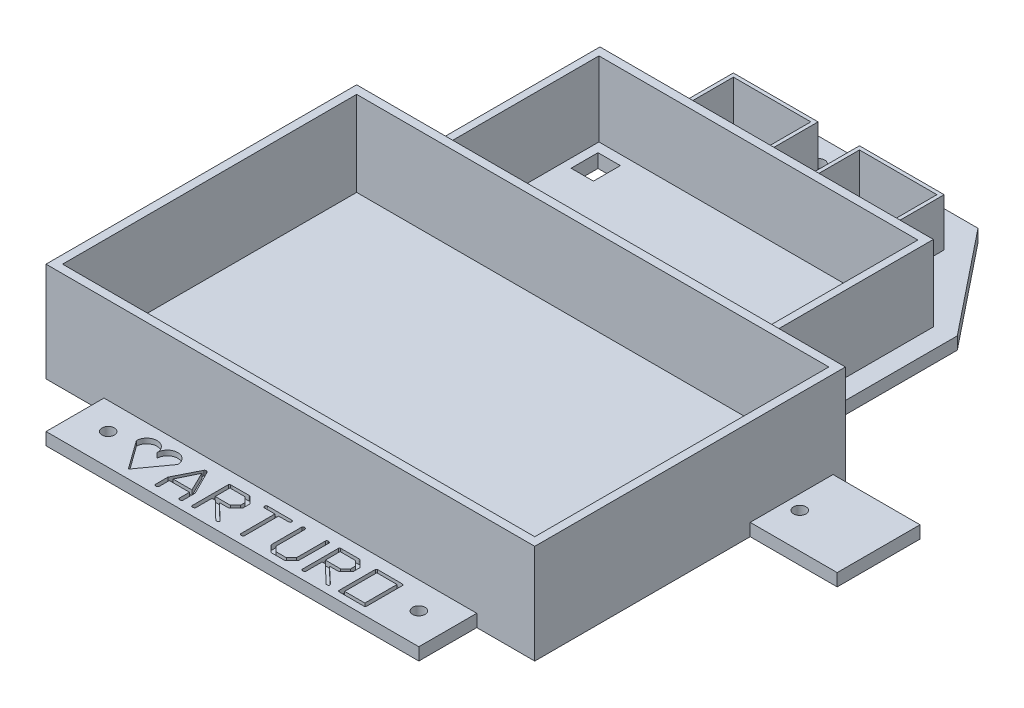
from build123d import *

# Parameters (mm, degrees)
SKETCH1_W           = 90
SKETCH1_H           = 145
BOSS_EXTRUDE1_DEPTH = 3
SKETCH3_W           = 35
SKETCH3_H           = 20
BOSS_EXTRUDE2_DEPTH = 3
SKETCH2_R           = 1.5
CUT_EXTRUDE1_DEPTH  = 3
SKETCH24_W          = 4.877009242
SKETCH24_H          = 7.758878341
CUT_EXTRUDE10_DEPTH = 1.2
SKETCH25_R          = 1.5
CUT_EXTRUDE11_DEPTH = 192.465401715
SKETCH27_W          = 80.5
SKETCH27_H          = 40
BOSS_EXTRUDE4_DEPTH = 18.3
SKETCH28_W          = 77
SKETCH28_H          = 36
CUT_EXTRUDE12_DEPTH = 18
SKETCH29_W          = 5.4
SKETCH29_H          = 6.5
CUT_EXTRUDE13_DEPTH = 18
SKETCH31_W          = 118
SKETCH31_H          = 75
BOSS_EXTRUDE5_DEPTH = 3
SKETCH32_W          = 118
SKETCH32_H          = 75
BOSS_EXTRUDE6_DEPTH = 18
SKETCH33_W          = 114
SKETCH33_H          = 71
CUT_EXTRUDE14_DEPTH = 20.5
SKETCH34_W          = 90
SKETCH34_H          = 3
BOSS_EXTRUDE7_DEPTH = 10
SKETCH35_W          = 20.45
SKETCH35_H          = 14.75
BOSS_EXTRUDE8_DEPTH = 11.55
SKETCH36_W          = 18.7
SKETCH36_H          = 13
CUT_EXTRUDE15_DEPTH = 11.55
CUT_EXTRUDE16_DEPTH = 11.55
CUT_EXTRUDE17_DEPTH = 11.55
SKETCH39_R          = 1.5
CUT_EXTRUDE19_DEPTH = 10


with BuildPart() as part:
    # Sketch1 → Boss-Extrude1 (new body)
    with BuildSketch(Plane(origin=(0, 0, 0), x_dir=(1, 0, 0), z_dir=(0, 1, 0))):
        with Locations((45, 72.5)):
            Rectangle(SKETCH1_W, SKETCH1_H)
    extrude(amount=BOSS_EXTRUDE1_DEPTH)

    # Sketch3 → Boss-Extrude2 (add)
    with BuildSketch(Plane(origin=(0, 3, 0), x_dir=(1, 0, 0), z_dir=(0, 1, 0))):
        with Locations((107.5, 76)):
            Rectangle(SKETCH3_W, SKETCH3_H)
        with Locations((-17.5, 76)):
            Rectangle(SKETCH3_W, SKETCH3_H)
    extrude(amount=-BOSS_EXTRUDE2_DEPTH)

    # Sketch2 → Cut-Extrude1 (cut)
    with BuildSketch(Plane(origin=(0, 3, 0), x_dir=(1, 0, 0), z_dir=(0, 1, 0))):
        with Locations(Location((7.5, 7.5, 0), (0, 0, 270))):
            Circle(SKETCH2_R)
        with Locations(Location((82.5, 7.5, 0), (0, 0, 270))):
            Circle(SKETCH2_R)
    extrude(amount=-CUT_EXTRUDE1_DEPTH, mode=Mode.SUBTRACT)

    # Sketch24 → Cut-Extrude10 (cut)
    with BuildSketch(Plane(origin=(0, 3, 0), x_dir=(1, 0, 0), z_dir=(0, 1, 0))):
        with BuildLine():
            Line((12.8, 9.002960052), (17.8, 2.06645569))
            Line((17.8, 2.06645569), (22.8, 9.002960052))
            ThreePointArc((22.8, 9.002960052), (20.3, 11.502960052), (17.8, 9.002960052))
            ThreePointArc((17.8, 9.002960052), (15.3, 11.502960052), (12.8, 9.002960052))
        make_face()
        with BuildLine():
            Line((27.960572726, 10.919890082), (30.899594276, 5.112854575))
            Line((30.899594276, 5.112854575), (30.899594276, 2.165173562))
            add(Edge.make_bspline(
                [(30.899594276, 2.165173562), (30.892927247, 2.140068414), (30.879954851, 2.091219979), (30.846858341, 2.024032213), (30.800737443, 1.967188076), (30.742020239, 1.921417495), (30.671236475, 1.886557094), (30.588439852, 1.863302375), (30.494943384, 1.847264506), (30.42859556, 1.845629109), (30.39388167, 1.844773452)],
                knots=[0, 0, 0, 0, 0.947643866, 1.843881502, 2.713660738, 3.599912128, 4.543320166, 5.577847846, 6.732704141, 8, 8, 8, 8], degree=3))
            add(Edge.make_bspline(
                [(30.39388167, 1.844773452), (30.344182078, 1.848546499), (30.248653133, 1.855798777), (30.138847489, 1.908146199), (30.070730608, 1.973741423), (30.03673257, 2.042634219), (30.015862164, 2.12641683), (30.013917243, 2.18753699), (30.012865323, 2.220594122)],
                knots=[0, 0, 0, 0, 1.458306385, 2.803050631, 3.475744591, 4.205244022, 5.029297625, 6, 6, 6, 6], degree=3))
            Line((30.012865323, 2.220594122), (30.012865323, 4.615801431))
            Line((30.012865323, 4.615801431), (25.13585608, 4.615801431))
            Line((25.13585608, 4.615801431), (25.132392295, 2.13573139))
            add(Edge.make_bspline(
                [(25.132392295, 2.13573139), (25.1242737, 2.109421365), (25.107472305, 2.054972891), (25.046353025, 1.987225122), (24.967328767, 1.92496232), (24.90233253, 1.895330988), (24.867412745, 1.879411302)],
                knots=[0, 0, 0, 0, 0.85446616, 1.768313713, 2.801007444, 4, 4, 4, 4], degree=3))
            add(Edge.make_bspline(
                [(24.867412745, 1.879411302), (24.856639425, 1.873655896), (24.830690772, 1.859793408), (24.779197205, 1.852562961), (24.713555929, 1.844731283), (24.664262831, 1.84475846), (24.637071044, 1.844773452)],
                knots=[0, 0, 0, 0, 0.618990669, 1.490902888, 2.615894787, 4, 4, 4, 4], degree=3))
            add(Edge.make_bspline(
                [(24.637071044, 1.844773452), (24.609854685, 1.845658545), (24.557815716, 1.847350885), (24.483497085, 1.863312057), (24.416757888, 1.889580371), (24.356389001, 1.925640528), (24.30553323, 1.97679588), (24.273040413, 2.047007647), (24.25207084, 2.131613072), (24.250159634, 2.193881759), (24.249127127, 2.227521692)],
                knots=[0, 0, 0, 0, 1.042871789, 1.994020302, 2.898665572, 3.783582711, 4.676223712, 5.617005175, 6.71261484, 8, 8, 8, 8], degree=3))
            Line((24.249127127, 2.227521692), (24.249127127, 2.362609306))
            Line((24.249127127, 2.362609306), (24.249127127, 5.164811349))
            Line((24.249127127, 5.164811349), (27.182953, 10.975310642))
            add(Edge.make_bspline(
                [(27.182953, 10.975310642), (27.197877117, 10.993849349), (27.229358055, 11.032954903), (27.294231669, 11.082063278), (27.376505657, 11.122430618), (27.437855453, 11.143979663), (27.470447152, 11.155427461)],
                knots=[0, 0, 0, 0, 0.825089278, 1.740443647, 2.79962467, 4, 4, 4, 4], degree=3))
            add(Edge.make_bspline(
                [(27.470447152, 11.155427461), (27.528625563, 11.153661236), (27.636139052, 11.150397258), (27.780169754, 11.104934835), (27.896812425, 11.03137778), (27.93945397, 10.956817158), (27.960572726, 10.919890082)],
                knots=[0, 0, 0, 0, 1.208227024, 2.232799106, 3.124771774, 4, 4, 4, 4], degree=3))
        make_face()
        Polygon((25.262284232, 5.391689265), (29.825820934, 5.391689265), (27.531063389, 10.072994656), align=None, mode=Mode.SUBTRACT)
        with BuildLine():
            Line((38.216840032, 10.992629567), (39.737441636, 9.461636609))
            Line((39.737441636, 9.461636609), (39.766883808, 9.32308521))
            Line((39.766883808, 9.32308521), (39.76168813, 7.800751714))
            Line((39.76168813, 7.800751714), (39.735709743, 7.71415709))
            Line((39.735709743, 7.71415709), (38.111194591, 6.129475464))
            Line((38.111194591, 6.129475464), (37.892976137, 6.05673598))
            Line((37.892976137, 6.05673598), (35.778335411, 6.05673598))
            Line((35.778335411, 6.05673598), (39.720122711, 2.331435241))
            add(Edge.make_bspline(
                [(39.720122711, 2.331435241), (39.731087028, 2.299853317), (39.748714944, 2.249077376), (39.761899762, 2.196987509), (39.766883808, 2.17729681)],
                knots=[0, 0, 0, 0, 1.243971999, 2, 2, 2, 2], degree=3))
            add(Edge.make_bspline(
                [(39.766883808, 2.17729681), (39.766883808, 2.174265998), (39.766883808, 2.170224915), (39.766883808, 2.173111403), (39.766883808, 2.173833025)],
                knots=[0, 0, 0, 0, 1.5, 2, 2, 2, 2], degree=3))
            add(Edge.make_bspline(
                [(39.766883808, 2.173833025), (39.771715245, 2.160766102), (39.780766869, 2.136285421), (39.781815136, 2.097906565), (39.766653287, 2.064033831), (39.7485569, 2.048521029), (39.739173528, 2.040477303)],
                knots=[0, 0, 0, 0, 1.11883269, 2.096116091, 3.012794686, 4, 4, 4, 4], degree=3))
            add(Edge.make_bspline(
                [(39.739173528, 2.040477303), (39.727566205, 2.020510557), (39.70201817, 1.976563202), (39.632985413, 1.925524496), (39.540428519, 1.880986933), (39.468813666, 1.857678145), (39.429164773, 1.844773452)],
                knots=[0, 0, 0, 0, 0.72925176, 1.605103046, 2.67408771, 4, 4, 4, 4], degree=3))
            add(Edge.make_bspline(
                [(39.429164773, 1.844773452), (39.388098016, 1.845041005), (39.313253724, 1.845528621), (39.212689442, 1.858192852), (39.132980278, 1.873757432), (39.091720454, 1.89593355), (39.074126813, 1.905389689)],
                knots=[0, 0, 0, 0, 1.351550787, 2.463205539, 3.344694023, 4, 4, 4, 4], degree=3))
            Line((39.074126813, 1.905389689), (34.806743726, 6.05673598))
            Line((34.806743726, 6.05673598), (34.003145612, 6.05673598))
            Line((34.003145612, 6.05673598), (34.00141372, 2.140927067))
            add(Edge.make_bspline(
                [(34.00141372, 2.140927067), (33.995298712, 2.118873879), (33.981853518, 2.070385079), (33.925548243, 2.005981454), (33.845912839, 1.941976341), (33.780964357, 1.903902874), (33.745093632, 1.882875087)],
                knots=[0, 0, 0, 0, 0.725058933, 1.594202014, 2.671289696, 4, 4, 4, 4], degree=3))
            add(Edge.make_bspline(
                [(33.745093632, 1.882875087), (33.732616994, 1.876419845), (33.704345012, 1.861792309), (33.649847394, 1.854717867), (33.582714396, 1.844008135), (33.532155747, 1.844501964), (33.504360576, 1.844773452)],
                knots=[0, 0, 0, 0, 0.680304615, 1.541565885, 2.648448938, 4, 4, 4, 4], degree=3))
            add(Edge.make_bspline(
                [(33.504360576, 1.844773452), (33.477144217, 1.845658545), (33.425105248, 1.847350885), (33.350786617, 1.863312057), (33.28404742, 1.889580371), (33.223678533, 1.925640528), (33.172822762, 1.97679588), (33.140329944, 2.047007647), (33.119360372, 2.131613072), (33.117449166, 2.193881759), (33.116416659, 2.227521692)],
                knots=[0, 0, 0, 0, 1.042871789, 1.994020302, 2.898665572, 3.783582711, 4.676223712, 5.617005175, 6.71261484, 8, 8, 8, 8], degree=3))
            Line((33.116416659, 2.227521692), (33.116416659, 10.880056555))
            add(Edge.make_bspline(
                [(33.116416659, 10.880056555), (33.127738551, 10.909639319), (33.149713789, 10.967058014), (33.205196118, 11.039896555), (33.277004064, 11.096824962), (33.334391503, 11.117185129), (33.364077285, 11.127717181)],
                knots=[0, 0, 0, 0, 1.036233373, 2.011278177, 2.971259878, 4, 4, 4, 4], degree=3))
            Line((33.364077285, 11.127717181), (33.691404965, 11.143304213))
            Line((33.691404965, 11.143304213), (37.80464962, 11.155427461))
            add(Edge.make_bspline(
                [(37.80464962, 11.155427461), (37.848147953, 11.153572045), (37.929929714, 11.150083653), (38.044855449, 11.120440638), (38.143044379, 11.068947661), (38.192578769, 11.017720115), (38.216840032, 10.992629567)],
                knots=[0, 0, 0, 0, 1.138914518, 2.141287496, 3.08962818, 4, 4, 4, 4], degree=3))
        make_face()
        Polygon((38.880154855, 9.168946778), (37.667830114, 10.379539627), (34.003145612, 10.379539627), (34.003145612, 6.832623814), (37.657438759, 6.832623814), (38.880154855, 8.053608017), align=None, mode=Mode.SUBTRACT)
        with BuildLine():
            add(Edge.make_bspline(
                [(48.197736433, 11.139840428), (48.248814606, 11.129237205), (48.343120312, 11.109660457), (48.463854134, 11.043454426), (48.546553845, 10.945291148), (48.564471284, 10.866382142), (48.573557103, 10.826367888)],
                knots=[0, 0, 0, 0, 1.181692692, 2.181760989, 3.077982587, 4, 4, 4, 4], degree=3))
            add(Edge.make_bspline(
                [(48.573557103, 10.826367888), (48.573025472, 10.798496471), (48.571968338, 10.74307481), (48.549008491, 10.662747651), (48.516655543, 10.585261926), (48.46765368, 10.51200439), (48.39351601, 10.447249055), (48.284248258, 10.408281557), (48.146427953, 10.383035937), (48.043187783, 10.380779691), (47.98644555, 10.379539627)],
                knots=[0, 0, 0, 0, 0.786245999, 1.56343179, 2.346953672, 3.158622924, 4.039912103, 5.081205552, 6.395789976, 8, 8, 8, 8], degree=3))
            Line((47.98644555, 10.379539627), (45.752304242, 10.379539627))
            Line((45.752304242, 10.379539627), (45.752304242, 2.13573139))
            add(Edge.make_bspline(
                [(45.752304242, 2.13573139), (45.737834969, 2.096976441), (45.708739433, 2.019046056), (45.608004208, 1.930437564), (45.473792562, 1.870149939), (45.370273455, 1.853696233), (45.314135443, 1.844773452)],
                knots=[0, 0, 0, 0, 0.875438603, 1.760375598, 2.785460327, 4, 4, 4, 4], degree=3))
            add(Edge.make_bspline(
                [(45.314135443, 1.844773452), (45.282342843, 1.84583333), (45.221893507, 1.847848546), (45.135437701, 1.861253902), (45.058533468, 1.885937494), (44.988796901, 1.918959951), (44.932166785, 1.972224275), (44.891473443, 2.04426098), (44.870524312, 2.135772027), (44.867314145, 2.202025445), (44.865575289, 2.237913047)],
                knots=[0, 0, 0, 0, 1.106735935, 2.104308933, 3.032056499, 3.912699536, 4.765629981, 5.692724586, 6.750214194, 8, 8, 8, 8], degree=3))
            Line((44.865575289, 2.237913047), (44.865575289, 10.379539627))
            Line((44.865575289, 10.379539627), (42.305838193, 10.379539627))
            add(Edge.make_bspline(
                [(42.305838193, 10.379539627), (42.277120088, 10.381743601), (42.219340145, 10.386177929), (42.138420452, 10.42735916), (42.069387205, 10.495113529), (42.033878093, 10.551828043), (42.014880256, 10.582171048)],
                knots=[0, 0, 0, 0, 0.920024065, 1.85106007, 2.850289155, 4, 4, 4, 4], degree=3))
            add(Edge.make_bspline(
                [(42.014880256, 10.582171048), (42.00629867, 10.61489633), (41.990925206, 10.673521966), (41.985918233, 10.733887116), (41.983706191, 10.760555974)],
                knots=[0, 0, 0, 0, 1.116415417, 2, 2, 2, 2], degree=3))
            add(Edge.make_bspline(
                [(41.983706191, 10.760555974), (41.984537517, 10.787221897), (41.986125841, 10.838169579), (42.002598162, 10.909724604), (42.025803592, 10.97430869), (42.063514459, 11.028120753), (42.109238813, 11.074771128), (42.165782125, 11.110765019), (42.231657539, 11.139708174), (42.280159584, 11.149986023), (42.305838193, 11.155427461)],
                knots=[0, 0, 0, 0, 1.135223372, 2.16894787, 3.120179468, 4.042274884, 4.947778528, 5.890363842, 6.883087883, 8, 8, 8, 8], degree=3))
            Line((42.305838193, 11.155427461), (48.197736433, 11.139840428))
        make_face()
        with BuildLine():
            add(Edge.make_bspline(
                [(51.602637062, 11.039390664), (51.623400792, 11.018351255), (51.665842492, 10.975346059), (51.710198178, 10.89002461), (51.732828892, 10.787716362), (51.736029497, 10.714481552), (51.737724676, 10.675693242)],
                knots=[0, 0, 0, 0, 0.882650724, 1.804165135, 2.836991241, 4, 4, 4, 4], degree=3))
            Line((51.737724676, 10.675693242), (51.737724676, 3.787956822))
            Line((51.737724676, 3.787956822), (52.911947782, 2.620661286))
            Line((52.911947782, 2.620661286), (55.40414107, 2.620661286))
            Line((55.40414107, 2.620661286), (56.614733918, 3.834717919))
            Line((56.614733918, 3.834717919), (56.614733918, 10.899107373))
            add(Edge.make_bspline(
                [(56.614733918, 10.899107373), (56.632890994, 10.932991956), (56.667688855, 10.997931434), (56.742769473, 11.077647621), (56.836168491, 11.132180866), (56.906189354, 11.146407269), (56.942061598, 11.153695568)],
                knots=[0, 0, 0, 0, 1.060672957, 2.032769508, 2.992172196, 4, 4, 4, 4], degree=3))
            add(Edge.make_bspline(
                [(56.942061598, 11.153695568), (56.981935287, 11.152266103), (57.057568148, 11.149554677), (57.16653719, 11.131866055), (57.261552996, 11.094021015), (57.347659955, 11.046833201), (57.416735255, 10.978727797), (57.469426213, 10.893284471), (57.495287126, 10.787358437), (57.499320469, 10.712168382), (57.501462872, 10.672229457)],
                knots=[0, 0, 0, 0, 1.13662016, 2.155953935, 3.124124809, 4.037977889, 4.933445915, 5.855694631, 6.861002965, 8, 8, 8, 8], degree=3))
            Line((57.501462872, 10.672229457), (57.451237989, 3.462361035))
            Line((57.451237989, 3.462361035), (55.821527159, 1.867288055))
            Line((55.821527159, 1.867288055), (55.582525996, 1.844773452))
            Line((55.582525996, 1.844773452), (52.539590897, 1.844773452))
            Line((52.539590897, 1.844773452), (52.427017886, 1.920976722))
            Line((52.427017886, 1.920976722), (50.88390168, 3.467556712))
            Line((50.88390168, 3.467556712), (50.850995723, 3.630354606))
            Line((50.850995723, 3.630354606), (50.850995723, 10.892179803))
            add(Edge.make_bspline(
                [(50.850995723, 10.892179803), (50.86578812, 10.927355571), (50.894278256, 10.995104051), (50.968942603, 11.077439753), (51.067054906, 11.13055661), (51.140210444, 11.145769747), (51.178323403, 11.153695568)],
                knots=[0, 0, 0, 0, 1.028909836, 1.981678895, 2.948484413, 4, 4, 4, 4], degree=3))
            add(Edge.make_bspline(
                [(51.178323403, 11.153695568), (51.223443517, 11.152514399), (51.307885706, 11.150303844), (51.42499893, 11.130576304), (51.524113787, 11.094884658), (51.577304562, 11.057293656), (51.602637062, 11.039390664)],
                knots=[0, 0, 0, 0, 1.208192095, 2.261128696, 3.171849697, 4, 4, 4, 4], degree=3))
        make_face()
        with BuildLine():
            Line((64.818708628, 10.992629567), (66.339310231, 9.461636609))
            Line((66.339310231, 9.461636609), (66.368752403, 9.32308521))
            Line((66.368752403, 9.32308521), (66.363556726, 7.800751714))
            Line((66.363556726, 7.800751714), (66.337578339, 7.71415709))
            Line((66.337578339, 7.71415709), (64.713063186, 6.129475464))
            Line((64.713063186, 6.129475464), (64.494844733, 6.05673598))
            Line((64.494844733, 6.05673598), (62.380204007, 6.05673598))
            Line((62.380204007, 6.05673598), (66.321991306, 2.331435241))
            add(Edge.make_bspline(
                [(66.321991306, 2.331435241), (66.332955623, 2.299853317), (66.350583539, 2.249077376), (66.363768357, 2.196987509), (66.368752403, 2.17729681)],
                knots=[0, 0, 0, 0, 1.243971999, 2, 2, 2, 2], degree=3))
            add(Edge.make_bspline(
                [(66.368752403, 2.17729681), (66.368752403, 2.174265998), (66.368752403, 2.170224915), (66.368752403, 2.173111403), (66.368752403, 2.173833025)],
                knots=[0, 0, 0, 0, 1.5, 2, 2, 2, 2], degree=3))
            add(Edge.make_bspline(
                [(66.368752403, 2.173833025), (66.373583841, 2.160766102), (66.382635465, 2.136285421), (66.383683732, 2.097906565), (66.368521883, 2.064033831), (66.350425495, 2.048521029), (66.341042124, 2.040477303)],
                knots=[0, 0, 0, 0, 1.11883269, 2.096116091, 3.012794686, 4, 4, 4, 4], degree=3))
            add(Edge.make_bspline(
                [(66.341042124, 2.040477303), (66.329434801, 2.020510557), (66.303886766, 1.976563202), (66.234854008, 1.925524496), (66.142297114, 1.880986933), (66.070682262, 1.857678145), (66.031033369, 1.844773452)],
                knots=[0, 0, 0, 0, 0.72925176, 1.605103046, 2.67408771, 4, 4, 4, 4], degree=3))
            add(Edge.make_bspline(
                [(66.031033369, 1.844773452), (65.989966612, 1.845041005), (65.915122319, 1.845528621), (65.814558037, 1.858192852), (65.734848874, 1.873757432), (65.693589049, 1.89593355), (65.675995409, 1.905389689)],
                knots=[0, 0, 0, 0, 1.351550787, 2.463205539, 3.344694023, 4, 4, 4, 4], degree=3))
            Line((65.675995409, 1.905389689), (61.408612322, 6.05673598))
            Line((61.408612322, 6.05673598), (60.605014208, 6.05673598))
            Line((60.605014208, 6.05673598), (60.603282315, 2.140927067))
            add(Edge.make_bspline(
                [(60.603282315, 2.140927067), (60.597167307, 2.118873879), (60.583722113, 2.070385079), (60.527416839, 2.005981454), (60.447781435, 1.941976341), (60.382832952, 1.903902874), (60.346962227, 1.882875087)],
                knots=[0, 0, 0, 0, 0.725058933, 1.594202014, 2.671289696, 4, 4, 4, 4], degree=3))
            add(Edge.make_bspline(
                [(60.346962227, 1.882875087), (60.334485589, 1.876419845), (60.306213607, 1.861792309), (60.25171599, 1.854717867), (60.184582991, 1.844008135), (60.134024342, 1.844501964), (60.106229172, 1.844773452)],
                knots=[0, 0, 0, 0, 0.680304615, 1.541565885, 2.648448938, 4, 4, 4, 4], degree=3))
            add(Edge.make_bspline(
                [(60.106229172, 1.844773452), (60.079012812, 1.845658545), (60.026973843, 1.847350885), (59.952655213, 1.863312057), (59.885916015, 1.889580371), (59.825547129, 1.925640528), (59.774691357, 1.97679588), (59.74219854, 2.047007647), (59.721228968, 2.131613072), (59.719317761, 2.193881759), (59.718285255, 2.227521692)],
                knots=[0, 0, 0, 0, 1.042871789, 1.994020302, 2.898665572, 3.783582711, 4.676223712, 5.617005175, 6.71261484, 8, 8, 8, 8], degree=3))
            Line((59.718285255, 2.227521692), (59.718285255, 10.880056555))
            add(Edge.make_bspline(
                [(59.718285255, 10.880056555), (59.729607147, 10.909639319), (59.751582385, 10.967058014), (59.807064714, 11.039896555), (59.878872659, 11.096824962), (59.936260099, 11.117185129), (59.96594588, 11.127717181)],
                knots=[0, 0, 0, 0, 1.036233373, 2.011278177, 2.971259878, 4, 4, 4, 4], degree=3))
            Line((59.96594588, 11.127717181), (60.29327356, 11.143304213))
            Line((60.29327356, 11.143304213), (64.406518216, 11.155427461))
            add(Edge.make_bspline(
                [(64.406518216, 11.155427461), (64.450016548, 11.153572045), (64.531798309, 11.150083653), (64.646724044, 11.120440638), (64.744912975, 11.068947661), (64.794447365, 11.017720115), (64.818708628, 10.992629567)],
                knots=[0, 0, 0, 0, 1.138914518, 2.141287496, 3.08962818, 4, 4, 4, 4], degree=3))
        make_face()
        Polygon((65.48202345, 9.168946778), (64.26969871, 10.379539627), (60.605014208, 10.379539627), (60.605014208, 6.832623814), (64.259307355, 6.832623814), (65.48202345, 8.053608017), align=None, mode=Mode.SUBTRACT)
        with BuildLine():
            add(Edge.make_bspline(
                [(74.872344513, 11.141572321), (74.917954597, 11.130654942), (75.002830944, 11.110338661), (75.113095511, 11.056016493), (75.195226305, 10.979572999), (75.222484374, 10.91542576), (75.236041935, 10.88352034)],
                knots=[0, 0, 0, 0, 1.198848019, 2.230950549, 3.120113869, 4, 4, 4, 4], degree=3))
            Line((75.236041935, 10.88352034), (75.236041935, 10.673961349))
            Line((75.236041935, 10.673961349), (75.23257815, 2.140927067))
            add(Edge.make_bspline(
                [(75.23257815, 2.140927067), (75.224646811, 2.116039226), (75.207750171, 2.063019066), (75.152300742, 1.992187906), (75.075063377, 1.924775524), (75.012241674, 1.88757213), (74.977989955, 1.867288055)],
                knots=[0, 0, 0, 0, 0.810066725, 1.725736988, 2.760023768, 4, 4, 4, 4], degree=3))
            Line((74.977989955, 1.867288055), (74.813460169, 1.844773452))
            Line((74.813460169, 1.844773452), (68.834967304, 1.844773452))
            add(Edge.make_bspline(
                [(68.834967304, 1.844773452), (68.805392619, 1.858600534), (68.74893592, 1.88499579), (68.677051959, 1.943044593), (68.619511242, 2.012591087), (68.596935768, 2.06800907), (68.585574786, 2.095897863)],
                knots=[0, 0, 0, 0, 1.069880941, 2.042352972, 3.014825004, 4, 4, 4, 4], degree=3))
            Line((68.585574786, 2.095897863), (68.585574786, 2.362609306))
            Line((68.585574786, 2.362609306), (68.585574786, 10.892179803))
            add(Edge.make_bspline(
                [(68.585574786, 10.892179803), (68.597620512, 10.922708884), (68.621770589, 10.983915632), (68.693012817, 11.058461124), (68.785264924, 11.118876496), (68.858413187, 11.142737517), (68.897315434, 11.155427461)],
                knots=[0, 0, 0, 0, 0.917586887, 1.839639645, 2.85106129, 4, 4, 4, 4], degree=3))
            Line((68.897315434, 11.155427461), (74.872344513, 11.141572321))
        make_face()
        with Locations((71.910808361, 6.500100457)):
            Rectangle(SKETCH24_W, SKETCH24_H, mode=Mode.SUBTRACT)
    extrude(amount=-CUT_EXTRUDE10_DEPTH, mode=Mode.SUBTRACT)

    # Sketch25 → Cut-Extrude11 (cut, through all)
    with BuildSketch(Plane(origin=(0, 3, 0), x_dir=(1, 0, 0), z_dir=(0, 1, 0))):
        with Locations(Location((-17.46875749, 74.5, 0), (0, 0, 270))):
            Circle(SKETCH25_R)
        with Locations(Location((107.46875749, 74.5, 0), (0, 0, 270))):
            Circle(SKETCH25_R)
    extrude(amount=-CUT_EXTRUDE11_DEPTH, mode=Mode.SUBTRACT)

    # Sketch27 → Boss-Extrude4 (add)
    with BuildSketch(Plane(origin=(0, 3, 0), x_dir=(1, 0, 0), z_dir=(0, 1, 0))):
        with Locations((45, 108.98)):
            Rectangle(SKETCH27_W, SKETCH27_H)
    extrude(amount=BOSS_EXTRUDE4_DEPTH)

    # Sketch28 → Cut-Extrude12 (cut)
    with BuildSketch(Plane(origin=(0, 21.3, 0), x_dir=(1, 0, 0), z_dir=(0, 1, 0))):
        with Locations((45, 108.98)):
            Rectangle(SKETCH28_W, SKETCH28_H)
    extrude(amount=-CUT_EXTRUDE12_DEPTH, mode=Mode.SUBTRACT)

    # Sketch29 → Cut-Extrude13 (cut)
    with BuildSketch(Plane(origin=(0, 3.3, 0), x_dir=(1, 0, 0), z_dir=(0, 1, 0))):
        with Locations((11.329537264, 121.373034792)):
            Rectangle(SKETCH29_W, SKETCH29_H)
    extrude(amount=-CUT_EXTRUDE13_DEPTH, mode=Mode.SUBTRACT)

    # Sketch31 → Boss-Extrude5 (add, symmetric)
    with BuildSketch(Plane(origin=(0, 3, 0), x_dir=(1, 0, 0), z_dir=(0, 1, 0))):
        with Locations((45, 51.484507375)):
            Rectangle(SKETCH31_W, SKETCH31_H)
    extrude(amount=BOSS_EXTRUDE5_DEPTH, both=True)

    # Sketch32 → Boss-Extrude6 (add)
    with BuildSketch(Plane(origin=(0, 6, 0), x_dir=(1, 0, 0), z_dir=(0, 1, 0))):
        with Locations((45, 51.484507375)):
            Rectangle(SKETCH32_W, SKETCH32_H)
    extrude(amount=BOSS_EXTRUDE6_DEPTH)

    # Sketch33 → Cut-Extrude14 (cut, symmetric)
    with BuildSketch(Plane(origin=(0, 24, 0), x_dir=(1, 0, 0), z_dir=(0, 1, 0))):
        with Locations((45, 51.484507375)):
            Rectangle(SKETCH33_W, SKETCH33_H)
    extrude(amount=CUT_EXTRUDE14_DEPTH, both=True, mode=Mode.SUBTRACT)

    # Sketch34 → Boss-Extrude7 (add)
    with BuildSketch(Plane(origin=(0, 0, -145), x_dir=(-1, 0, 0), z_dir=(0, 0, -1))):
        with Locations((-45, 1.5)):
            Rectangle(SKETCH34_W, SKETCH34_H)
    extrude(amount=BOSS_EXTRUDE7_DEPTH)

    # Sketch35 → Boss-Extrude8 (add)
    with BuildSketch(Plane(origin=(0, 3, 0), x_dir=(1, 0, 0), z_dir=(0, 1, 0))):
        with Locations((29.775, 139.009793879)):
            Rectangle(SKETCH35_W, SKETCH35_H)
        with Locations((60.225, 139.009793879)):
            Rectangle(SKETCH35_W, SKETCH35_H)
    extrude(amount=BOSS_EXTRUDE8_DEPTH)

    # Sketch36 → Cut-Extrude15 (cut)
    with BuildSketch(Plane(origin=(0, 14.55, 0), x_dir=(1, 0, 0), z_dir=(0, 1, 0))):
        with Locations((29.775, 139.009793879)):
            Rectangle(SKETCH36_W, SKETCH36_H)
        with Locations((60.225, 139.009793879)):
            Rectangle(SKETCH36_W, SKETCH36_H)
    extrude(amount=-CUT_EXTRUDE15_DEPTH, mode=Mode.SUBTRACT)

    # Sketch37 → Cut-Extrude16 (cut)
    with BuildSketch(Plane(origin=(0, 3, 0), x_dir=(1, 0, 0), z_dir=(0, 1, 0))):
        with BuildLine():
            Line((28.925, 134.759793879), (38.625, 134.759793879))
            Line((38.625, 134.759793879), (38.625, 143.259793879))
            Line((38.625, 143.259793879), (28.925, 143.259793879))
            ThreePointArc((28.925, 143.259793879), (24.675, 139.009793879), (28.925, 134.759793879))
        make_face()
        with BuildLine():
            Line((59.375, 134.759793879), (69.075, 134.759793879))
            Line((69.075, 134.759793879), (69.075, 143.259793879))
            Line((69.075, 143.259793879), (59.375, 143.259793879))
            ThreePointArc((59.375, 143.259793879), (55.125, 139.009793879), (59.375, 134.759793879))
        make_face()
    extrude(amount=-CUT_EXTRUDE16_DEPTH, mode=Mode.SUBTRACT)

    # Sketch38 → Cut-Extrude17 (cut)
    with BuildSketch(Plane(origin=(0, 3, 0), x_dir=(1, 0, 0), z_dir=(0, 1, 0))):
        Polygon((20, 155), (0, 130), (0, 155), align=None)
        Polygon((70, 155), (90, 130), (90, 155), align=None)
    extrude(amount=-CUT_EXTRUDE17_DEPTH, mode=Mode.SUBTRACT)

    # Sketch39 → Cut-Extrude19 (cut)
    with BuildSketch(Plane(origin=(0, 3, 0), x_dir=(1, 0, 0), z_dir=(0, 1, 0))):
        with Locations(Location((37.25, 149.255779875, 0), (0, 0, 270))):
            Circle(SKETCH39_R)
        with Locations(Location((52.75, 149.255779875, 0), (0, 0, 270))):
            Circle(SKETCH39_R)
    extrude(amount=-CUT_EXTRUDE19_DEPTH, mode=Mode.SUBTRACT)


solid = part.part
